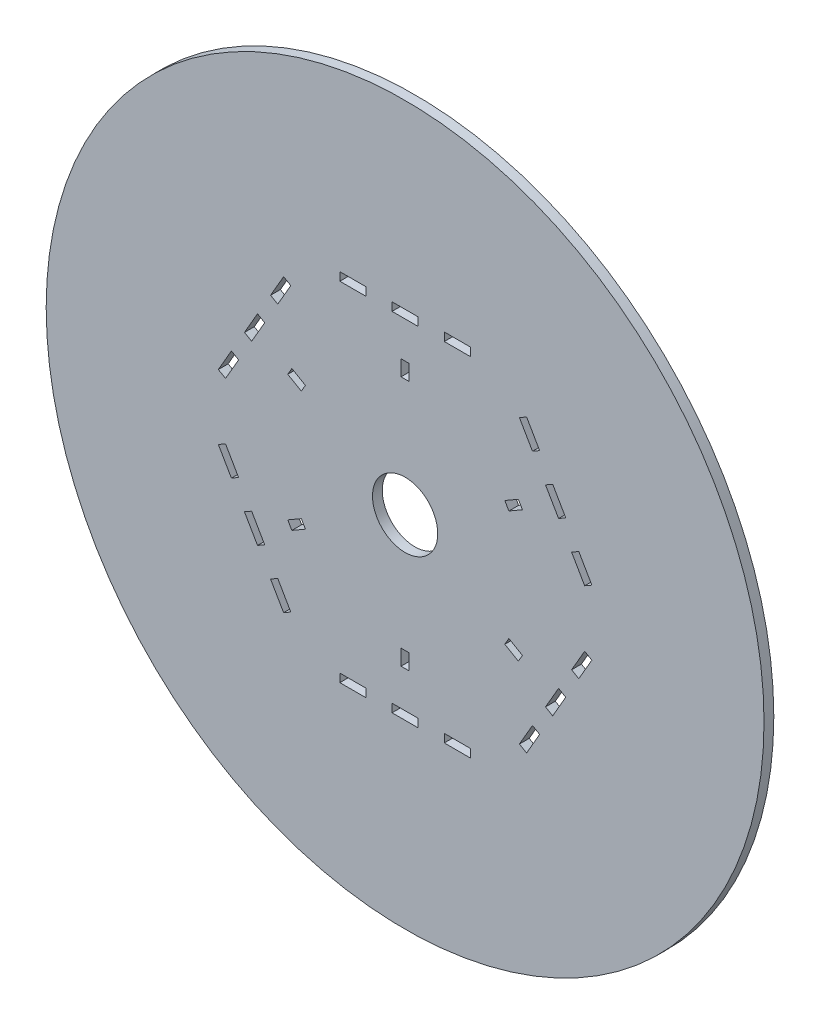
from build123d import *

# Parameters (mm, degrees)
SKETCH1_R           = 137.5
SKETCH1_R_2         = 12.5
SKETCH1_W           = 10
SKETCH1_H           = 3.175
SKETCH1_W_2         = 3.125
SKETCH1_H_2         = 6
BOSS_EXTRUDE1_DEPTH = 1.875


with BuildPart() as part:
    # Sketch1 → Boss-Extrude1 (new body, symmetric)
    with BuildSketch(Plane.XY):
        Circle(SKETCH1_R)
        Circle(SKETCH1_R_2, mode=Mode.SUBTRACT)
        with Locations((0, 66.5875)):
            Rectangle(SKETCH1_W, SKETCH1_H, mode=Mode.SUBTRACT)
        with Locations((-20, 66.5875)):
            Rectangle(SKETCH1_W, SKETCH1_H, mode=Mode.SUBTRACT)
        with Locations((20, 66.5875)):
            Rectangle(SKETCH1_W, SKETCH1_H, mode=Mode.SUBTRACT)
        with Locations((0, 48)):
            Rectangle(SKETCH1_W_2, SKETCH1_H_2, mode=Mode.SUBTRACT)
        Polygon((61.541281903, 29.757372981), (56.541281903, 38.417627019), (53.791651246, 36.830127019), (58.791651246, 28.169872981), align=None, mode=Mode.SUBTRACT)
        Polygon((51.541281903, 47.077881057), (46.541281903, 55.738135095), (43.791651246, 54.150635095), (48.791651246, 45.490381057), align=None, mode=Mode.SUBTRACT)
        Polygon((71.541281903, 12.436864905), (68.791651246, 10.849364905), (63.791651246, 19.509618943), (66.541281903, 21.097118943), align=None, mode=Mode.SUBTRACT)
        Polygon((44.948545593, 24.146835307), (43.386045593, 26.853164693), (38.18989317, 23.853164693), (39.75239317, 21.146835307), align=None, mode=Mode.SUBTRACT)
        Polygon((56.541281903, -38.417627019), (61.541281903, -29.757372981), (58.791651246, -28.169872981), (53.791651246, -36.830127019), align=None, mode=Mode.SUBTRACT)
        Polygon((66.541281903, -21.097118943), (71.541281903, -12.436864905), (68.791651246, -10.849364905), (63.791651246, -19.509618943), align=None, mode=Mode.SUBTRACT)
        Polygon((46.541281903, -55.738135095), (43.791651246, -54.150635095), (48.791651246, -45.490381057), (51.541281903, -47.077881057), align=None, mode=Mode.SUBTRACT)
        Polygon((43.386045593, -26.853164693), (44.948545593, -24.146835307), (39.75239317, -21.146835307), (38.18989317, -23.853164693), align=None, mode=Mode.SUBTRACT)
        with Locations((0, -66.5875)):
            Rectangle(SKETCH1_W, SKETCH1_H, mode=Mode.SUBTRACT)
        with Locations((20, -66.5875)):
            Rectangle(SKETCH1_W, SKETCH1_H, mode=Mode.SUBTRACT)
        with Locations((-20, -66.5875)):
            Rectangle(SKETCH1_W, SKETCH1_H, mode=Mode.SUBTRACT)
        with Locations((0, -48)):
            Rectangle(SKETCH1_W_2, SKETCH1_H_2, mode=Mode.SUBTRACT)
        Polygon((-61.541281903, -29.757372981), (-56.541281903, -38.417627019), (-53.791651246, -36.830127019), (-58.791651246, -28.169872981), align=None, mode=Mode.SUBTRACT)
        Polygon((-51.541281903, -47.077881057), (-46.541281903, -55.738135095), (-43.791651246, -54.150635095), (-48.791651246, -45.490381057), align=None, mode=Mode.SUBTRACT)
        Polygon((-71.541281903, -12.436864905), (-68.791651246, -10.849364905), (-63.791651246, -19.509618943), (-66.541281903, -21.097118943), align=None, mode=Mode.SUBTRACT)
        Polygon((-44.948545593, -24.146835307), (-43.386045593, -26.853164693), (-38.18989317, -23.853164693), (-39.75239317, -21.146835307), align=None, mode=Mode.SUBTRACT)
        Polygon((-56.541281903, 38.417627019), (-61.541281903, 29.757372981), (-58.791651246, 28.169872981), (-53.791651246, 36.830127019), align=None, mode=Mode.SUBTRACT)
        Polygon((-66.541281903, 21.097118943), (-71.541281903, 12.436864905), (-68.791651246, 10.849364905), (-63.791651246, 19.509618943), align=None, mode=Mode.SUBTRACT)
        Polygon((-46.541281903, 55.738135095), (-43.791651246, 54.150635095), (-48.791651246, 45.490381057), (-51.541281903, 47.077881057), align=None, mode=Mode.SUBTRACT)
        Polygon((-43.386045593, 26.853164693), (-44.948545593, 24.146835307), (-39.75239317, 21.146835307), (-38.18989317, 23.853164693), align=None, mode=Mode.SUBTRACT)
    extrude(amount=BOSS_EXTRUDE1_DEPTH, both=True)


solid = part.part
